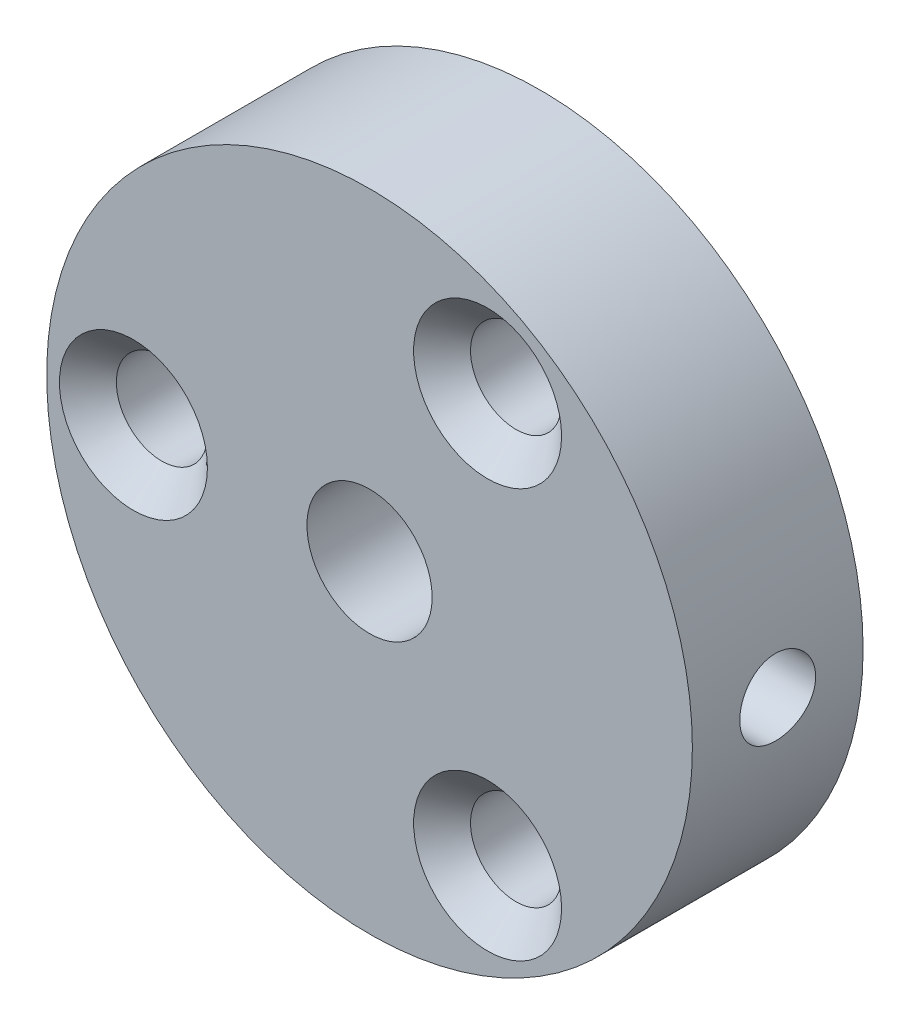
from build123d import *

# Parameters (mm, degrees)
SKETCH2_R             = 8.509
BOSS_EXTRUDE1_DEPTH   = 2.25
M2_CLEARANCE_HOLE1_D  = 2.4
CHAMFER1_SIZE         = 0.75
CHAMFER2_SIZE         = 0.75
CHAMFER3_SIZE         = 0.75
M4X0_7_TAPPED_HOLE1_D = 3.3
SKETCH11_R            = 1
CUT_EXTRUDE1_DEPTH    = 4.509


with BuildPart() as part:
    # Sketch2 → Boss-Extrude1 (new body, symmetric)
    with BuildSketch(Plane.XY):
        Circle(SKETCH2_R)
    extrude(amount=BOSS_EXTRUDE1_DEPTH, both=True)

    # M2 Clearance Hole1 (through all)
    with Locations(Plane.XY.offset(2.25)):
        with Locations((-6.223, 0), (3.1115, 5.389276088), (3.1115, -5.389276088)):
            Hole(M2_CLEARANCE_HOLE1_D / 2)

    # Chamfer1
    chamfer1_edges = [part.edges().sort_by_distance(p)[0] for p in [
        (4.3115, -5.389276088, 2.25),
    ]]
    chamfer(chamfer1_edges, length=CHAMFER1_SIZE)

    # Chamfer2
    chamfer2_edges = [part.edges().sort_by_distance(p)[0] for p in [
        (4.3115, 5.389276088, 2.25),
    ]]
    chamfer(chamfer2_edges, length=CHAMFER2_SIZE)

    # Chamfer3
    chamfer3_edges = [part.edges().sort_by_distance(p)[0] for p in [
        (-5.023, 0, 2.25),
    ]]
    chamfer(chamfer3_edges, length=CHAMFER3_SIZE)

    # M4x0.7 Tapped Hole1 (through all)
    with Locations(Plane.XY.offset(2.25)):
        with Locations((0, 0)):
            Hole(M4X0_7_TAPPED_HOLE1_D / 2)

    # Sketch11 → Cut-Extrude1 (cut, through all)
    with BuildSketch(Plane(origin=(5, 0, 0), x_dir=(0, 0, -1), z_dir=(1, 0, 0))):
        Circle(SKETCH11_R)
    extrude(amount=CUT_EXTRUDE1_DEPTH, mode=Mode.SUBTRACT)


solid = part.part
